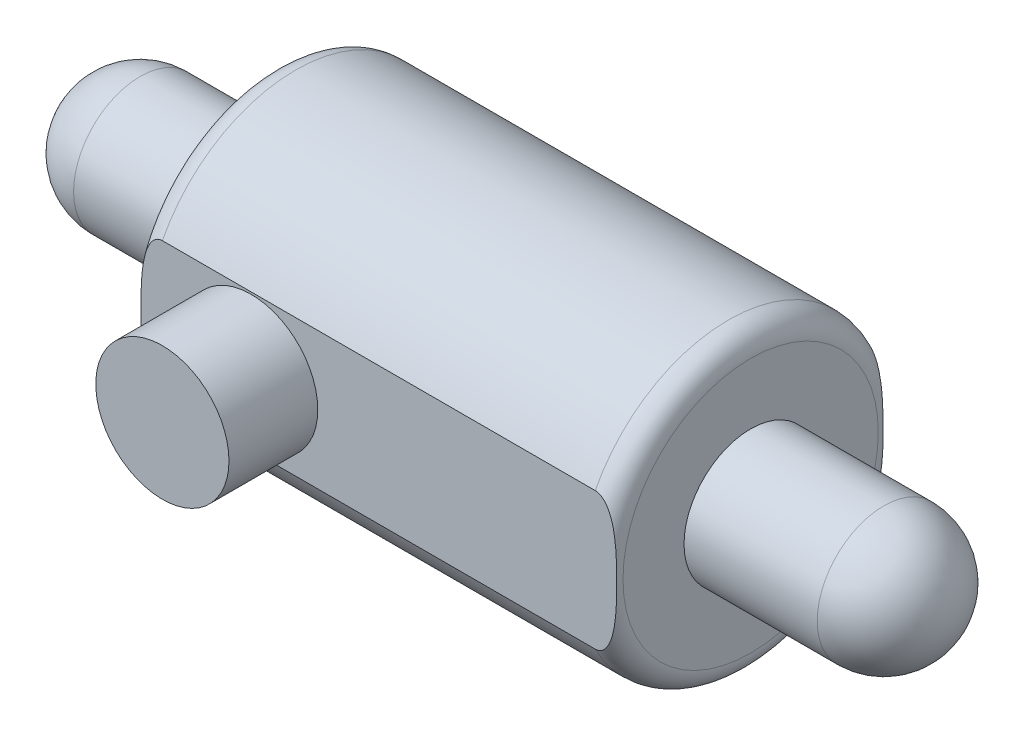
from build123d import *

# Parameters (mm, degrees)
SKETCH1_W           = 43
SKETCH1_H           = 13.5
SKETCH4_R           = 6
BOSS_EXTRUDE2_DEPTH = 20
SKETCH5_R           = 6
BOSS_EXTRUDE3_DEPTH = 18
FILLET1_R           = 6
BOSS_EXTRUDE4_START = 18
SKETCH6_R           = 6
BOSS_EXTRUDE4_DEPTH = 18
FILLET2_R           = 6
FILLET3_R           = 2
SKETCH8_W           = 43
SKETCH8_H           = 23
CUT_EXTRUDE2_DEPTH  = 7
SKETCH9_W           = 43
SKETCH9_H           = 23
SKETCH9_R           = 6
CUT_EXTRUDE3_DEPTH  = 5


with BuildPart() as part:
    # Sketch1 → Revolve1 (revolve)
    with BuildSketch(Plane(origin=(0, 0, 0), x_dir=(1, 0, 0), z_dir=(0, 1, 0))):
        with Locations((-25.810870043, -6.75)):
            Rectangle(SKETCH1_W, SKETCH1_H)
    revolve(axis=Axis((-47.310870043, 0, 0), (1, 0, 0)))

    # Sketch4 → Boss-Extrude2 (add)
    with BuildSketch(Plane.XY):
        with Locations((-37.310870043, 0)):
            Circle(SKETCH4_R)
    extrude(amount=BOSS_EXTRUDE2_DEPTH)

    # Sketch5 → Boss-Extrude3 (add)
    with BuildSketch(Plane.ZY.offset(47.310870043)):
        Circle(SKETCH5_R)
    extrude(amount=BOSS_EXTRUDE3_DEPTH)

    # Fillet1
    fillet1_edges = [part.edges().sort_by_distance(p)[0] for p in [
        (-65.310870043, 0, -6),
    ]]
    fillet(fillet1_edges, radius=FILLET1_R)

    # Sketch6 → Boss-Extrude4 (add)
    with BuildSketch(Plane(origin=(-4.310870043, 0, 0), x_dir=(0, 0, -1), z_dir=(1, 0, 0)).offset(BOSS_EXTRUDE4_START)):
        Circle(SKETCH6_R)
    extrude(amount=-BOSS_EXTRUDE4_DEPTH)

    # Fillet2
    fillet2_edges = [part.edges().sort_by_distance(p)[0] for p in [
        (13.689129957, 0, 6),
    ]]
    fillet(fillet2_edges, radius=FILLET2_R)

    # Fillet3
    fillet3_edges = [part.edges().sort_by_distance(p)[0] for p in [
        (-4.310870043, 0, -13.5),
        (-47.310870043, 0, -13.5),
    ]]
    fillet(fillet3_edges, radius=FILLET3_R)

    # Sketch8 → Cut-Extrude2 (cut)
    with BuildSketch(Plane.XY.offset(-12)):
        with Locations((-25.810870043, 0)):
            Rectangle(SKETCH8_W, SKETCH8_H)
    extrude(amount=-CUT_EXTRUDE2_DEPTH, mode=Mode.SUBTRACT)

    # Sketch9 → Cut-Extrude3 (cut)
    with BuildSketch(Plane.XY.offset(12)):
        with Locations((-25.810870043, 0)):
            Rectangle(SKETCH9_W, SKETCH9_H)
        with Locations((-37.310870043, 0)):
            Circle(SKETCH9_R, mode=Mode.SUBTRACT)
    extrude(amount=CUT_EXTRUDE3_DEPTH, mode=Mode.SUBTRACT)


solid = part.part
